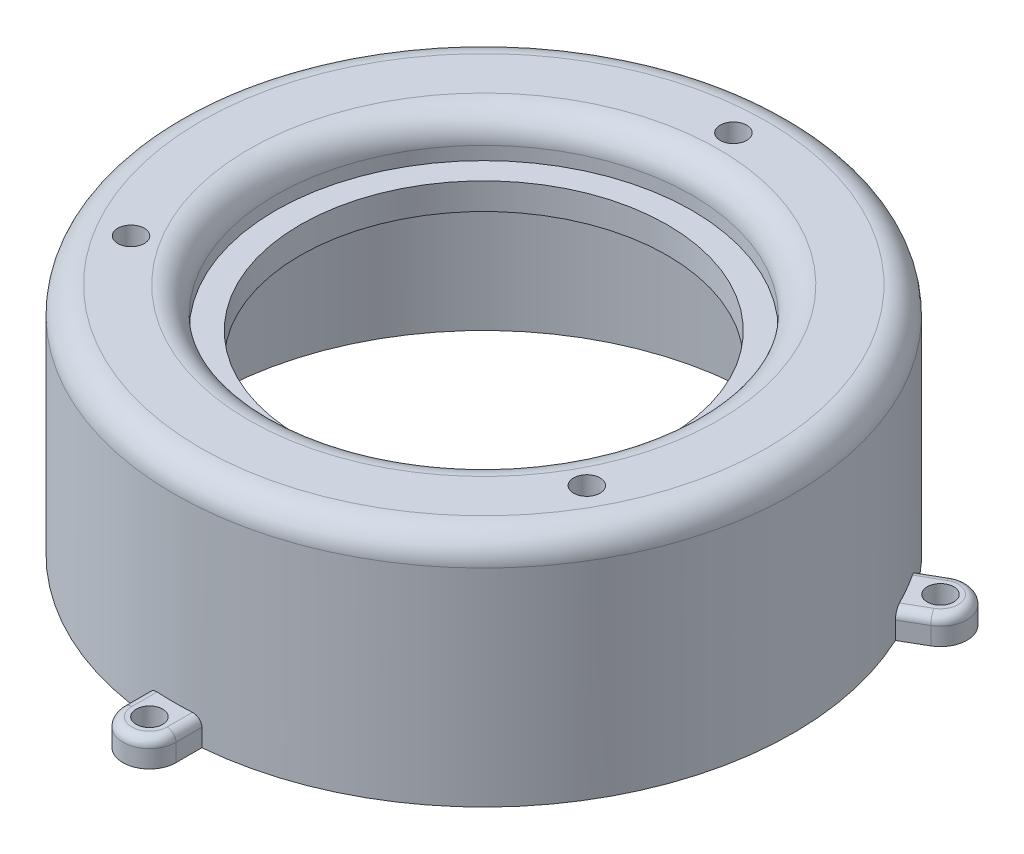
from build123d import *

# Parameters (mm, degrees)
SKETCH1_R                = 35
SKETCH1_R_2              = 2.6
SKETCH1_R_3              = 11
BOSS_EXTRUDE1_DEPTH      = 50
SKETCH2_R                = 31
CUT_EXTRUDE1_DEPTH       = 45
SKETCH3_R                = 26.05
SKETCH3_R_2              = 23.55
BOSS_EXTRUDE2_DEPTH      = 7.5
BOSS_EXTRUDE3_START      = -8
SKETCH5_R                = 23.55
SKETCH5_R_2              = 20.75
BOSS_EXTRUDE3_DEPTH      = 2
SKETCH7_R                = 35
SKETCH7_R_2              = 25.333529331
BOSS_EXTRUDE4_DEPTH      = 7.5
SKETCH9_R                = 31
SKETCH9_R_2              = 26.05
CUT_EXTRUDE2_DEPTH       = 10
FILLET1_R                = 3
SKETCH11_R               = 26.883478625
CUT_EXTRUDE4_DEPTH       = 404
SKETCH12_R               = 1.5
CUT_EXTRUDE5_DEPTH       = 7
CUT_EXTRUDE6_DEPTH       = 7
CIRPATTERN1_COUNT        = 3
SKETCH15_R               = 26.05
SKETCH15_R_2             = 20.75
BOSS_EXTRUDE5_DEPTH      = 3
SKETCH10_W               = 144.751988019
SKETCH10_H               = 48.841098946
CUT_EXTRUDE7_DEPTH       = 93
CUT_EXTRUDE7_DEPTH_BACK  = 113
SKETCH16_R               = 1.5
BOSS_EXTRUDE6_DEPTH      = 3
FILLET3_R                = 1
CIRPATTERN7_COUNT        = 3
FILLET3_OF_CIRPATTERN7_R = 1


with BuildPart() as part:
    # Sketch1 → Boss-Extrude1 (new body)
    with BuildSketch(Plane(origin=(0, 0, 0), x_dir=(1, 0, 0), z_dir=(0, 1, 0))):
        Circle(SKETCH1_R)
        with Locations((-8.350111435, 15.379390073)):
            Circle(SKETCH1_R_2, mode=Mode.SUBTRACT)
        with Locations((-9.143886781, -14.921103663)):
            Circle(SKETCH1_R_2, mode=Mode.SUBTRACT)
        with Locations((17.493998216, -0.45828641)):
            Circle(SKETCH1_R_2, mode=Mode.SUBTRACT)
        Circle(SKETCH1_R_3, mode=Mode.SUBTRACT)
    extrude(amount=BOSS_EXTRUDE1_DEPTH)

    # Sketch2 → Cut-Extrude1 (cut)
    with BuildSketch(Plane.XZ):
        Circle(SKETCH2_R)
    extrude(amount=-CUT_EXTRUDE1_DEPTH, mode=Mode.SUBTRACT)

    # Sketch3 → Boss-Extrude2 (add)
    with BuildSketch(Plane(origin=(0, 50, 0), x_dir=(1, 0, 0), z_dir=(0, 1, 0))):
        with Locations((0, 0.716470669)):
            Circle(SKETCH3_R)
        Circle(SKETCH3_R_2, mode=Mode.SUBTRACT)
    extrude(amount=BOSS_EXTRUDE2_DEPTH)

    # Sketch5 → Boss-Extrude3 (add)
    with BuildSketch(Plane(origin=(0, 57.5, 0), x_dir=(1, 0, 0), z_dir=(0, 1, 0)).offset(BOSS_EXTRUDE3_START)):
        Circle(SKETCH5_R)
        Circle(SKETCH5_R_2, mode=Mode.SUBTRACT)
    extrude(amount=BOSS_EXTRUDE3_DEPTH)

    # Sketch7 → Boss-Extrude4 (add)
    with BuildSketch(Plane(origin=(0, 50, 0), x_dir=(1, 0, 0), z_dir=(0, 1, 0))):
        Circle(SKETCH7_R)
        Circle(SKETCH7_R_2, mode=Mode.SUBTRACT)
    extrude(amount=BOSS_EXTRUDE4_DEPTH)

    # Sketch9 → Cut-Extrude2 (cut)
    with BuildSketch(Plane.XZ.offset(-45)):
        Circle(SKETCH9_R)
        Circle(SKETCH9_R_2, mode=Mode.SUBTRACT)
    extrude(amount=-CUT_EXTRUDE2_DEPTH, mode=Mode.SUBTRACT)

    # Fillet1
    fillet1_edges = [part.edges().sort_by_distance(p)[0] for p in [
        (-23.55, 57.5, 0),
        (-35, 57.5, 0),
    ]]
    fillet(fillet1_edges, radius=FILLET1_R)

    # Sketch11 → Cut-Extrude4 (cut)
    with BuildSketch(Plane(origin=(0, 50, 0), x_dir=(1, 0, 0), z_dir=(0, 1, 0))):
        Circle(SKETCH11_R)
    extrude(amount=-CUT_EXTRUDE4_DEPTH, mode=Mode.SUBTRACT)

    # Sketch12 → Cut-Extrude5 (cut)
    with BuildSketch(Plane(origin=(0, 57.5, 0), x_dir=(1, 0, 0), z_dir=(0, 1, 0))):
        with Locations((-0.762925985, 28.989962814)):
            Circle(SKETCH12_R)
    cut_extrude5 = extrude(amount=-CUT_EXTRUDE5_DEPTH, mode=Mode.SUBTRACT)

    # Sketch13 → Cut-Extrude6 (cut)
    with BuildSketch(Plane.XZ.offset(-55)):
        Polygon((-3.995941284, -28.959215343), (-2.406061725, -31.774462459), (0.826953574, -31.805209929), (2.470089315, -29.020710284), (0.880209755, -26.205463169), (-2.352805544, -26.174715698), align=None)
    cut_extrude6 = extrude(amount=CUT_EXTRUDE6_DEPTH, mode=Mode.SUBTRACT)

    # CirPattern1: Cut-Extrude5, Cut-Extrude6 ×3 about axis
    cirpattern1_axis = Axis((0, 0, 0), (0, 1, 0))
    for i in range(1, CIRPATTERN1_COUNT):
        add(cut_extrude5.rotate(cirpattern1_axis, i * 360 / CIRPATTERN1_COUNT), mode=Mode.SUBTRACT)
        add(cut_extrude6.rotate(cirpattern1_axis, i * 360 / CIRPATTERN1_COUNT), mode=Mode.SUBTRACT)

    # Sketch15 → Boss-Extrude5 (add)
    with BuildSketch(Plane.XZ.offset(-50)):
        Circle(SKETCH15_R)
        Circle(SKETCH15_R_2, mode=Mode.SUBTRACT)
    extrude(amount=-BOSS_EXTRUDE5_DEPTH)

    # Sketch10 → Cut-Extrude7 (cut, two sides)
    with BuildSketch(Plane(origin=(0, 0, 0), x_dir=(0, 0, -1), z_dir=(1, 0, 0))) as cut_extrude7_sk:
        with Locations((-1.20572645, 6.679450527)):
            Rectangle(SKETCH10_W, SKETCH10_H)
    extrude(amount=CUT_EXTRUDE7_DEPTH, mode=Mode.SUBTRACT)
    extrude(cut_extrude7_sk.sketch, amount=-CUT_EXTRUDE7_DEPTH_BACK, mode=Mode.SUBTRACT)

    # Sketch16 → Boss-Extrude6 (add)
    with BuildSketch(Plane.XZ.offset(-31.1)):
        with BuildLine():
            Line((-3, 34.871191548), (-3, 37.8))
            ThreePointArc((-3, 37.8), (0, 40.8), (3, 37.8))
            Line((3, 37.8), (3, 34.871191548))
            Line((3, 34.871191548), (-3, 34.871191548))
        make_face()
        with Locations((0, 37.8)):
            Circle(SKETCH16_R, mode=Mode.SUBTRACT)
    boss_extrude6 = extrude(amount=-BOSS_EXTRUDE6_DEPTH)

    # Fillet3
    fillet3_edges = [part.edges().sort_by_distance(p)[0] for p in [
        (-3, 34.1, 36.335595774),
        (0, 34.1, 40.8),
        (3, 34.1, 36.335595774),
    ]]
    fillet(fillet3_edges, radius=FILLET3_R)

    # CirPattern7: Boss-Extrude6 ×3 about axis
    cirpattern7_axis = Axis((0, 0, 0), (0, 1, 0))
    for i in range(1, CIRPATTERN7_COUNT):
        add(boss_extrude6.rotate(cirpattern7_axis, i * 360 / CIRPATTERN7_COUNT))

    # Fillet3 of CirPattern7
    fillet3_of_cirpattern7_edges = [part.edges().sort_by_distance(p)[0] for p in [
        (32.967549002, 34.1, -15.569721676),
        (35.333836474, 34.1, -20.4),
        (29.967549002, 34.1, -20.765874098),
        (-29.967549002, 34.1, -20.765874098),
        (-35.333836474, 34.1, -20.4),
        (-32.967549002, 34.1, -15.569721676),
    ]]
    fillet(fillet3_of_cirpattern7_edges, radius=FILLET3_OF_CIRPATTERN7_R)


solid = part.part
